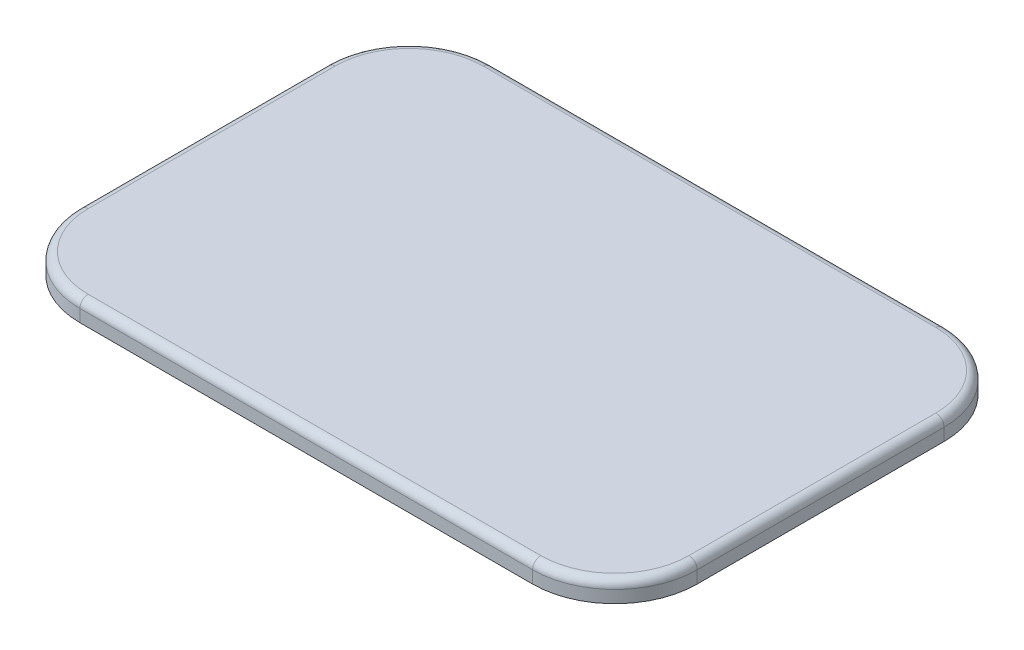
from build123d import *

# Parameters (mm, degrees)
DODANIE_WYCI_GNI_CIE1_DEPTH = 10
ZAOKR_GLENIE1_R             = 4


with BuildPart() as part:
    # Szkic1 → Dodanie-wyciągnięcie1 (new body)
    with BuildSketch(Plane(origin=(0, 0, 0), x_dir=(1, 0, 0), z_dir=(0, 1, 0))):
        with BuildLine():
            Line((-110, -100), (110, -100))
            ThreePointArc((110, -100), (138.284271247, -88.284271247), (150, -60))
            Line((150, -60), (150, 60))
            ThreePointArc((150, 60), (138.284271247, 88.284271247), (110, 100))
            Line((110, 100), (-110, 100))
            ThreePointArc((-110, 100), (-138.284271247, 88.284271247), (-150, 60))
            Line((-150, 60), (-150, -60))
            ThreePointArc((-150, -60), (-138.284271247, -88.284271247), (-110, -100))
        make_face()
    extrude(amount=DODANIE_WYCI_GNI_CIE1_DEPTH)

    # Zaokrąglenie1
    zaokr_glenie1_edges = [part.edges().sort_by_distance(p)[0] for p in [
        (-138.284271247, 10, -88.284271247),
        (-150, 10, 0),
        (-138.284271247, 10, 88.284271247),
        (0, 10, 100),
        (138.284271247, 10, 88.284271247),
        (150, 10, 0),
        (138.284271247, 10, -88.284271247),
        (0, 10, -100),
    ]]
    fillet(zaokr_glenie1_edges, radius=ZAOKR_GLENIE1_R)


solid = part.part
